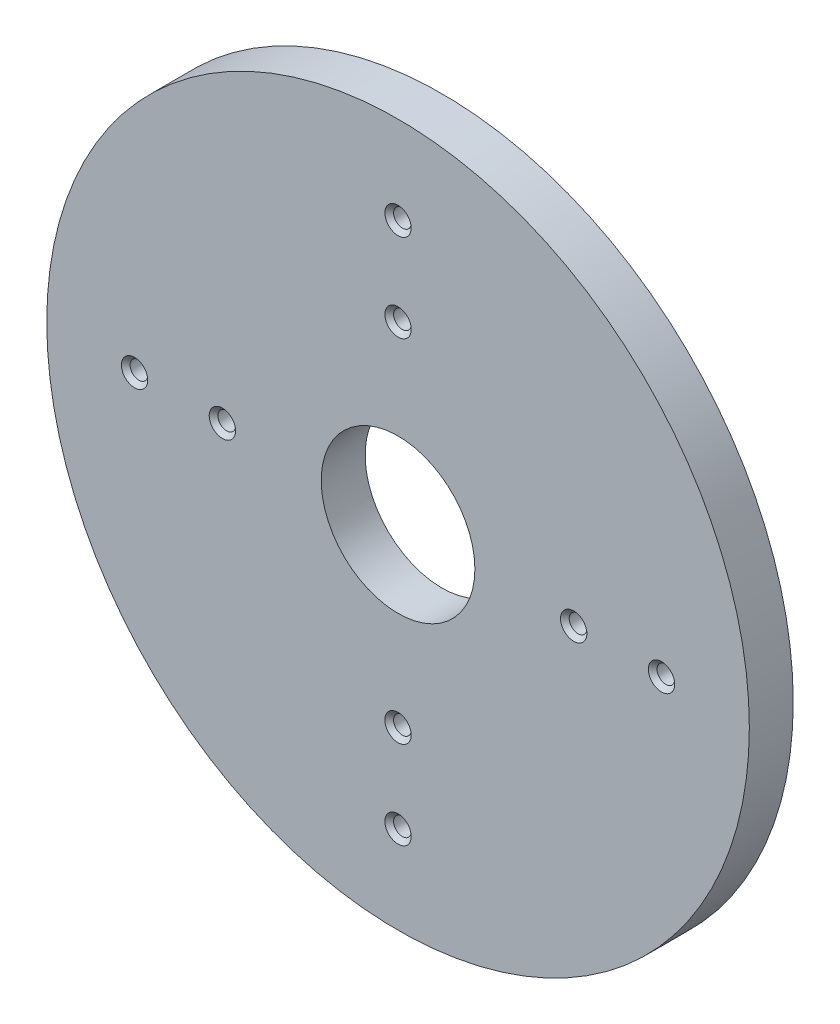
from build123d import *

# Parameters (mm, degrees)
SKETCH1_R                        = 101.6
SKETCH1_R_2                      = 22.225
BOSS_EXTRUDE1_DEPTH              = 12.7
F_1_4_20_TAPPED_HOLE1_AT_2_COUNT = 2
F_1_4_20_TAPPED_HOLE1_AT_2_PITCH = 91.581002397
F_1_4_20_TAPPED_HOLE1_AT_3_COUNT = 2
F_1_4_20_TAPPED_HOLE1_AT_3_PITCH = 71.842048969
F_1_4_20_TAPPED_HOLE1_AT_4_COUNT = 2
F_1_4_20_TAPPED_HOLE1_AT_4_PITCH = 127
F_1_4_20_TAPPED_HOLE1_AT_5_COUNT = 2
F_1_4_20_TAPPED_HOLE1_AT_5_PITCH = 101.6
F_1_4_20_TAPPED_HOLE1_AT_6_COUNT = 2
F_1_4_20_TAPPED_HOLE1_AT_6_PITCH = 91.581002397
F_1_4_20_TAPPED_HOLE1_AT_7_COUNT = 2
F_1_4_20_TAPPED_HOLE1_AT_7_PITCH = 71.842048969
F_1_4_20_TAPPED_HOLE1_AT_8_COUNT = 2
F_1_4_20_TAPPED_HOLE1_AT_8_PITCH = 25.4


with BuildPart() as part:
    # Sketch1 → Boss-Extrude1 (new body)
    with BuildSketch(Plane.XY):
        Circle(SKETCH1_R)
        Circle(SKETCH1_R_2, mode=Mode.SUBTRACT)
    extrude(amount=BOSS_EXTRUDE1_DEPTH)

    # Sketch3 → 1_4-20 Tapped Hole1 (revolve, cut)
    with BuildSketch(Plane(origin=(-50.8, 0, 12.7), x_dir=(0, -1, 0), z_dir=(1, 0, 0))):
        Polygon((0, 0), (0, 12.7), (3.81, 12.7), (2.5527, 11.4427), (2.5527, 1.2573), (3.81, 0), align=None)
    f_1_4_20_tapped_hole1 = revolve(axis=Axis((-50.8, 0, 19.05), (0, 0, -1)), mode=Mode.SUBTRACT)

    # 1_4-20 Tapped Hole1 at 2: 1_4-20 Tapped Hole1 ×2
    with Locations(*[Vector(0.554700196, 0.832050294, 0) * (i * F_1_4_20_TAPPED_HOLE1_AT_2_PITCH) for i in range(1, F_1_4_20_TAPPED_HOLE1_AT_2_COUNT)]):
        add(f_1_4_20_tapped_hole1, mode=Mode.SUBTRACT)

    # 1_4-20 Tapped Hole1 at 3: 1_4-20 Tapped Hole1 ×2
    with Locations(*[Vector(0.707106781, 0.707106781, 0) * (i * F_1_4_20_TAPPED_HOLE1_AT_3_PITCH) for i in range(1, F_1_4_20_TAPPED_HOLE1_AT_3_COUNT)]):
        add(f_1_4_20_tapped_hole1, mode=Mode.SUBTRACT)

    # 1_4-20 Tapped Hole1 at 4: 1_4-20 Tapped Hole1 ×2
    with Locations(*[(i * F_1_4_20_TAPPED_HOLE1_AT_4_PITCH, 0, 0) for i in range(1, F_1_4_20_TAPPED_HOLE1_AT_4_COUNT)]):
        add(f_1_4_20_tapped_hole1, mode=Mode.SUBTRACT)

    # 1_4-20 Tapped Hole1 at 5: 1_4-20 Tapped Hole1 ×2
    with Locations(*[(i * F_1_4_20_TAPPED_HOLE1_AT_5_PITCH, 0, 0) for i in range(1, F_1_4_20_TAPPED_HOLE1_AT_5_COUNT)]):
        add(f_1_4_20_tapped_hole1, mode=Mode.SUBTRACT)

    # 1_4-20 Tapped Hole1 at 6: 1_4-20 Tapped Hole1 ×2
    with Locations(*[Vector(0.554700196, -0.832050294, 0) * (i * F_1_4_20_TAPPED_HOLE1_AT_6_PITCH) for i in range(1, F_1_4_20_TAPPED_HOLE1_AT_6_COUNT)]):
        add(f_1_4_20_tapped_hole1, mode=Mode.SUBTRACT)

    # 1_4-20 Tapped Hole1 at 7: 1_4-20 Tapped Hole1 ×2
    with Locations(*[Vector(0.707106781, -0.707106781, 0) * (i * F_1_4_20_TAPPED_HOLE1_AT_7_PITCH) for i in range(1, F_1_4_20_TAPPED_HOLE1_AT_7_COUNT)]):
        add(f_1_4_20_tapped_hole1, mode=Mode.SUBTRACT)

    # 1_4-20 Tapped Hole1 at 8: 1_4-20 Tapped Hole1 ×2
    with Locations(*[(-i * F_1_4_20_TAPPED_HOLE1_AT_8_PITCH, 0, 0) for i in range(1, F_1_4_20_TAPPED_HOLE1_AT_8_COUNT)]):
        add(f_1_4_20_tapped_hole1, mode=Mode.SUBTRACT)


solid = part.part
